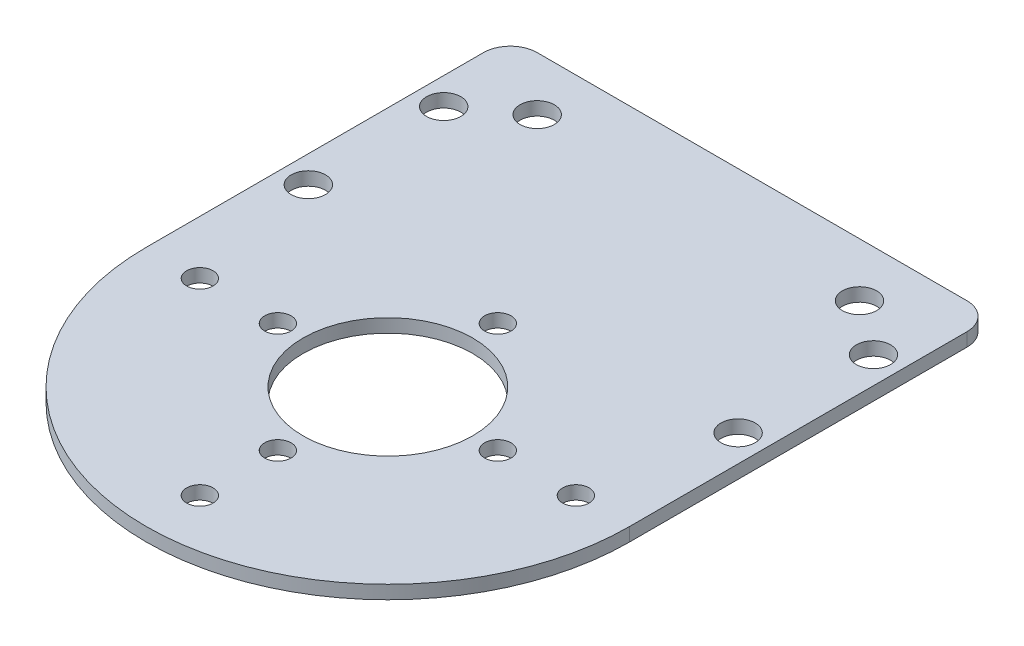
from build123d import *

# Parameters (mm, degrees)
SKETCH1_R           = 10.025
SKETCH1_R_2         = 1.5625
SKETCH1_R_3         = 2.025
BOSS_EXTRUDE1_DEPTH = 1.5875


with BuildPart() as part:
    # Sketch1 → Boss-Extrude1 (new body)
    with BuildSketch(Plane(origin=(0, 0, 0), x_dir=(1, 0, 0), z_dir=(0, 1, 0))):
        with BuildLine():
            Line((-28.575, 0), (-28.575, 39.875))
            ThreePointArc((-28.575, 39.875), (-27.64506403, 42.12006403), (-25.4, 43.05))
            Line((-25.4, 43.05), (25.4, 43.05))
            ThreePointArc((25.4, 43.05), (27.64506403, 42.12006403), (28.575, 39.875))
            Line((28.575, 39.875), (28.575, 0))
            ThreePointArc((28.575, 0), (0, -28.575), (-28.575, 0))
        make_face()
        Circle(SKETCH1_R, mode=Mode.SUBTRACT)
        with Locations((0, -13)):
            Circle(SKETCH1_R_2, mode=Mode.SUBTRACT)
        with Locations((-13, 0)):
            Circle(SKETCH1_R_2, mode=Mode.SUBTRACT)
        with Locations((0, 13)):
            Circle(SKETCH1_R_2, mode=Mode.SUBTRACT)
        with Locations((13, 0)):
            Circle(SKETCH1_R_2, mode=Mode.SUBTRACT)
        with Locations((-22.225, 0)):
            Circle(SKETCH1_R_2, mode=Mode.SUBTRACT)
        with Locations((0, -22.225)):
            Circle(SKETCH1_R_2, mode=Mode.SUBTRACT)
        with Locations((22.225, 0)):
            Circle(SKETCH1_R_2, mode=Mode.SUBTRACT)
        with Locations((-25.4, 16)):
            Circle(SKETCH1_R_3, mode=Mode.SUBTRACT)
        with Locations((25.4, 16)):
            Circle(SKETCH1_R_3, mode=Mode.SUBTRACT)
        with Locations((25.4, 32)):
            Circle(SKETCH1_R_3, mode=Mode.SUBTRACT)
        with Locations((-25.4, 32)):
            Circle(SKETCH1_R_3, mode=Mode.SUBTRACT)
        with Locations((-19.05, 36.7)):
            Circle(SKETCH1_R_3, mode=Mode.SUBTRACT)
        with Locations((19.05, 36.7)):
            Circle(SKETCH1_R_3, mode=Mode.SUBTRACT)
    extrude(amount=BOSS_EXTRUDE1_DEPTH)


solid = part.part
